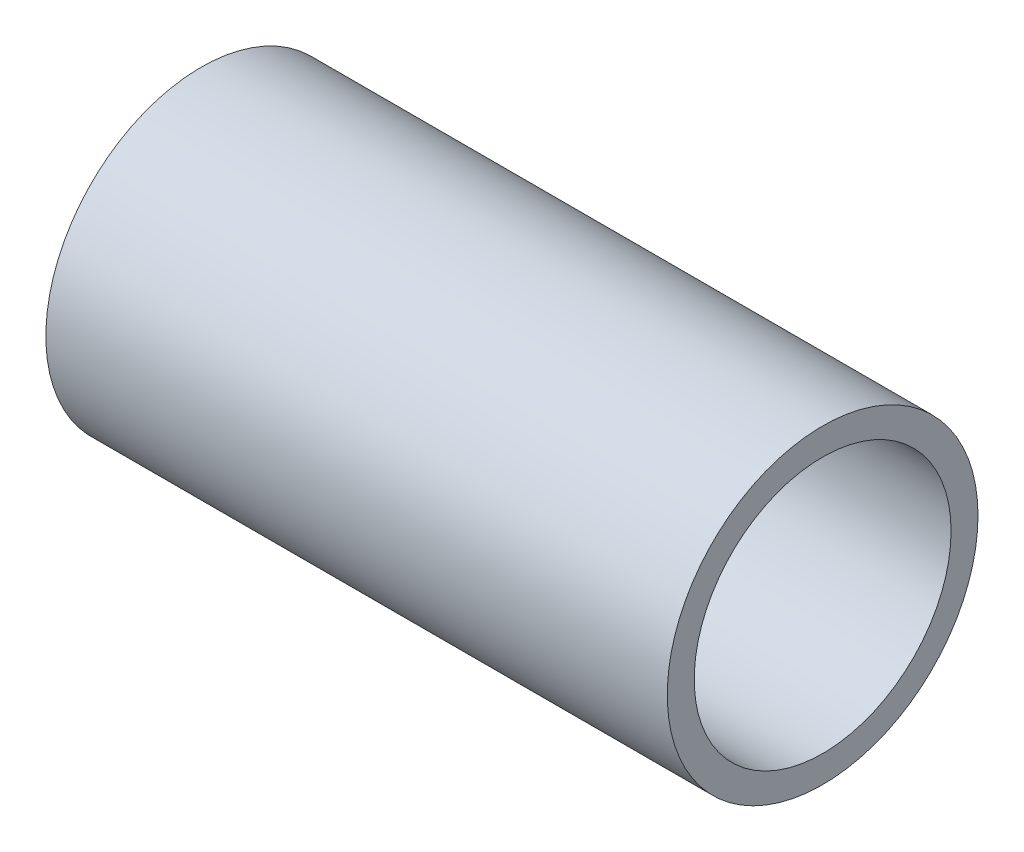
from build123d import *

# Parameters (mm, degrees)
SKETCH1_R           = 9.525
SKETCH1_R_2         = 7.874
BOSS_EXTRUDE1_DEPTH = 19.05


with BuildPart() as part:
    # Sketch1 → Boss-Extrude1 (new body, symmetric)
    with BuildSketch(Plane(origin=(0, 0, 0), x_dir=(0, 0, -1), z_dir=(1, 0, 0))):
        Circle(SKETCH1_R)
        Circle(SKETCH1_R_2, mode=Mode.SUBTRACT)
    extrude(amount=BOSS_EXTRUDE1_DEPTH, both=True)


solid = part.part
